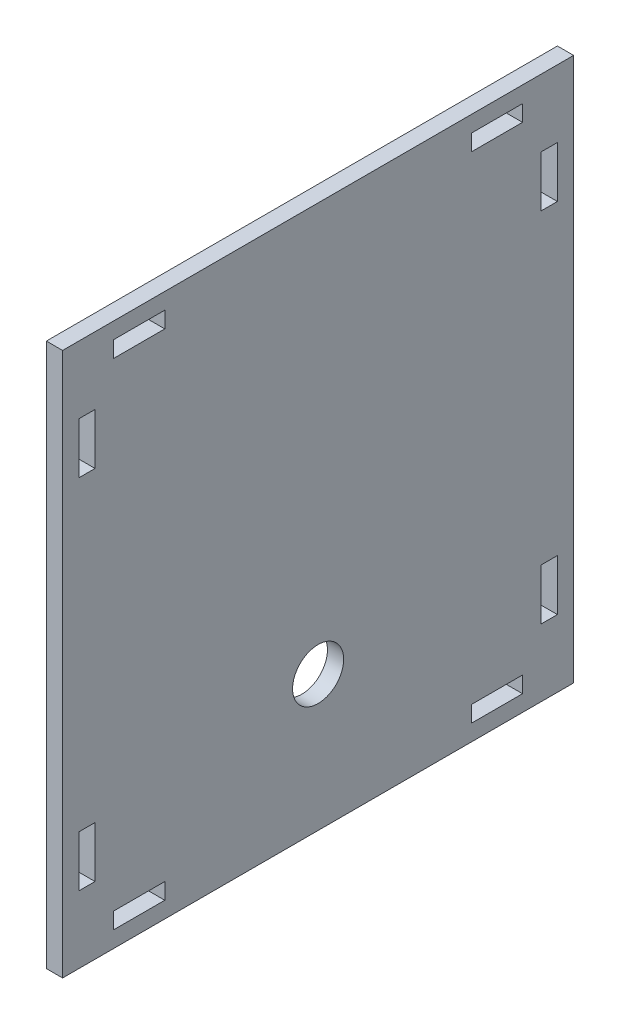
from build123d import *

# Parameters (mm, degrees)
SKETCH1_W           = 100
SKETCH1_H           = 106.35
SKETCH1_R           = 5
SKETCH1_W_2         = 3.175
SKETCH1_H_2         = 10
SKETCH1_W_3         = 10
SKETCH1_H_3         = 3.175
BOSS_EXTRUDE1_DEPTH = 3.175


with BuildPart() as part:
    # Sketch1 → Boss-Extrude1 (new body)
    with BuildSketch(Plane(origin=(0, 0, 0), x_dir=(0, 0, -1), z_dir=(1, 0, 0))):
        with Locations((50, 53.175)):
            Rectangle(SKETCH1_W, SKETCH1_H)
        with Locations((50, 26.509283713)):
            Circle(SKETCH1_R, mode=Mode.SUBTRACT)
        with Locations((4.7625, 88.175)):
            Rectangle(SKETCH1_W_2, SKETCH1_H_2, mode=Mode.SUBTRACT)
        with Locations((15, 101.5875)):
            Rectangle(SKETCH1_W_3, SKETCH1_H_3, mode=Mode.SUBTRACT)
        with Locations((85, 101.5875)):
            Rectangle(SKETCH1_W_3, SKETCH1_H_3, mode=Mode.SUBTRACT)
        with Locations((95.2375, 88.175)):
            Rectangle(SKETCH1_W_2, SKETCH1_H_2, mode=Mode.SUBTRACT)
        with Locations((95.2375, 18.175)):
            Rectangle(SKETCH1_W_2, SKETCH1_H_2, mode=Mode.SUBTRACT)
        with Locations((85, 4.7625)):
            Rectangle(SKETCH1_W_3, SKETCH1_H_3, mode=Mode.SUBTRACT)
        with Locations((15, 4.7625)):
            Rectangle(SKETCH1_W_3, SKETCH1_H_3, mode=Mode.SUBTRACT)
        with Locations((4.7625, 18.175)):
            Rectangle(SKETCH1_W_2, SKETCH1_H_2, mode=Mode.SUBTRACT)
    extrude(amount=BOSS_EXTRUDE1_DEPTH)


solid = part.part
